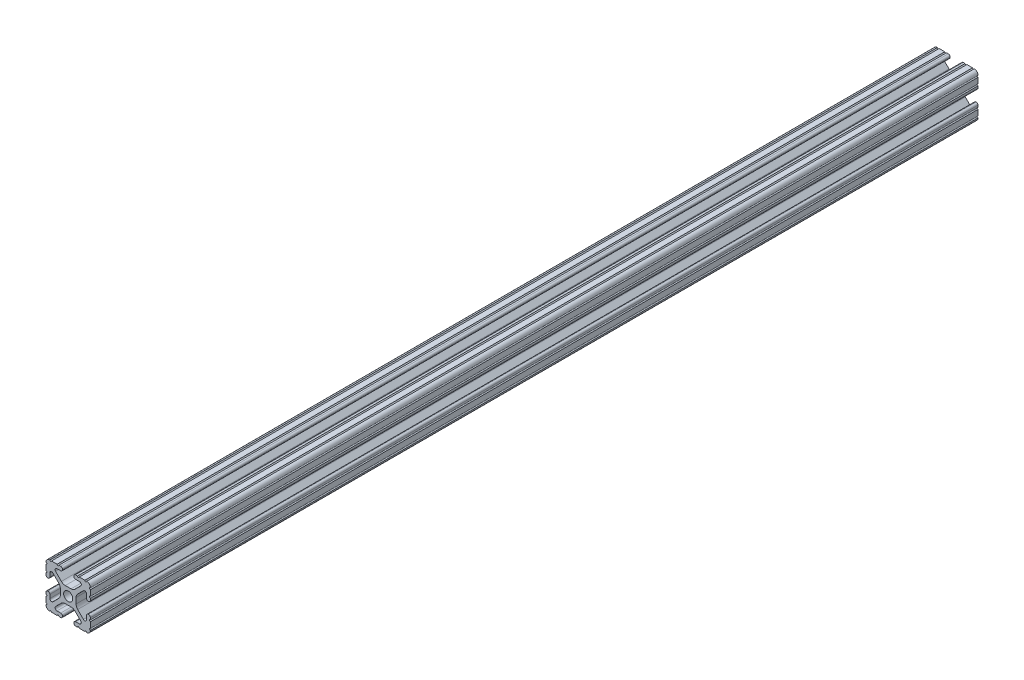
from build123d import *

# Parameters (mm, degrees)
SKETCH1_R           = 2.6035
BOSS_EXTRUDE1_DEPTH = 254


with BuildPart() as part:
    # Sketch1 → Boss-Extrude1 (new body, symmetric)
    with BuildSketch(Plane.XY):
        with BuildLine():
            Line((-7.179650497, -8.645192506), (-3.952270251, -5.423690499))
            ThreePointArc((-3.952270251, -5.423690499), (-2.922936451, -4.736929036), (-1.709253557, -4.4958))
            Line((-1.709253557, -4.4958), (1.709253557, -4.4958))
            ThreePointArc((1.709253557, -4.4958), (2.922936451, -4.736929036), (3.952270251, -5.423690499))
            Line((3.952270251, -5.423690499), (7.179650497, -8.645192506))
            ThreePointArc((7.179650497, -8.645192506), (7.41473083, -9.822813117), (6.416408329, -10.4902))
            Line((6.416408329, -10.4902), (4.287512407, -10.4902))
            ThreePointArc((4.287512407, -10.4902), (3.54574862, -10.79744862), (3.2385, -11.539212407))
            Line((3.2385, -11.539212407), (3.2385, -11.650987593))
            ThreePointArc((3.2385, -11.650987593), (3.54574862, -12.39275138), (4.287512407, -12.7))
            Line((4.287512407, -12.7), (5.317126718, -12.7))
            ThreePointArc((5.317126718, -12.7), (5.825126718, -12.192), (6.333126718, -12.7))
            Line((6.333126718, -12.7), (9.550443118, -12.7))
            ThreePointArc((9.550443118, -12.7), (10.058366869, -12.192000006), (10.566443095, -12.699847501))
            ThreePointArc((10.566443095, -12.699847501), (12.082537762, -12.08250727), (12.699846982, -10.566399977))
            ThreePointArc((12.699846982, -10.566399977), (12.192000006, -10.058323491), (12.7, -9.5504))
            Line((12.7, -9.5504), (12.7, -6.3330836))
            ThreePointArc((12.7, -6.3330836), (12.192, -5.8250836), (12.7, -5.3170836))
            Line((12.7, -5.3170836), (12.7, -4.287469289))
            ThreePointArc((12.7, -4.287469289), (12.39275138, -3.545705502), (11.650987593, -3.238456882))
            Line((11.650987593, -3.238456882), (11.539212407, -3.238456882))
            ThreePointArc((11.539212407, -3.238456882), (10.79744862, -3.545705502), (10.4902, -4.287469289))
            Line((10.4902, -4.287469289), (10.4902, -6.402089023))
            ThreePointArc((10.4902, -6.402089023), (9.856505071, -7.351067942), (8.737131347, -7.129408934))
            Line((8.737131347, -7.129408934), (5.441005833, -3.840816462))
            ThreePointArc((5.441005833, -3.840816462), (4.750877967, -2.809883091), (4.5085, -1.593185507))
            Line((4.5085, -1.593185507), (4.5085, 1.593185507))
            ThreePointArc((4.5085, 1.593185507), (4.750877967, 2.809883091), (5.441005833, 3.840816462))
            Line((5.441005833, 3.840816462), (8.737131347, 7.129408934))
            ThreePointArc((8.737131347, 7.129408934), (9.856505071, 7.351067942), (10.4902, 6.402089023))
            Line((10.4902, 6.402089023), (10.4902, 4.287469289))
            ThreePointArc((10.4902, 4.287469289), (10.79744862, 3.545705502), (11.539212407, 3.238456882))
            Line((11.539212407, 3.238456882), (11.650987593, 3.238456882))
            ThreePointArc((11.650987593, 3.238456882), (12.39275138, 3.545705502), (12.7, 4.287469289))
            Line((12.7, 4.287469289), (12.7, 5.3170836))
            ThreePointArc((12.7, 5.3170836), (12.192, 5.8250836), (12.7, 6.3330836))
            Line((12.7, 6.3330836), (12.7, 9.5504))
            ThreePointArc((12.7, 9.5504), (12.192000006, 10.058323491), (12.699846982, 10.566399977))
            ThreePointArc((12.699846982, 10.566399977), (12.082537762, 12.08250727), (10.566443095, 12.699847501))
            ThreePointArc((10.566443095, 12.699847501), (10.058366869, 12.192000006), (9.550443118, 12.7))
            Line((9.550443118, 12.7), (6.333126718, 12.7))
            ThreePointArc((6.333126718, 12.7), (5.825126718, 12.192), (5.317126718, 12.7))
            Line((5.317126718, 12.7), (4.287512407, 12.7))
            ThreePointArc((4.287512407, 12.7), (3.54574862, 12.39275138), (3.2385, 11.650987593))
            Line((3.2385, 11.650987593), (3.2385, 11.539212407))
            ThreePointArc((3.2385, 11.539212407), (3.54574862, 10.79744862), (4.287512407, 10.4902))
            Line((4.287512407, 10.4902), (6.476788598, 10.4902))
            ThreePointArc((6.476788598, 10.4902), (7.432222385, 9.85140422), (7.207036008, 8.724370562))
            Line((7.207036008, 8.724370562), (3.898272566, 5.423169045))
            ThreePointArc((3.898272566, 5.423169045), (2.869120213, 4.736787962), (1.655778399, 4.4958))
            Line((1.655778399, 4.4958), (-1.655778399, 4.4958))
            ThreePointArc((-1.655778399, 4.4958), (-2.869120213, 4.736787962), (-3.898272566, 5.423169045))
            Line((-3.898272566, 5.423169045), (-7.207036008, 8.724370562))
            ThreePointArc((-7.207036008, 8.724370562), (-7.432222385, 9.85140422), (-6.476788598, 10.4902))
            Line((-6.476788598, 10.4902), (-4.287512407, 10.4902))
            ThreePointArc((-4.287512407, 10.4902), (-3.54574862, 10.79744862), (-3.2385, 11.539212407))
            Line((-3.2385, 11.539212407), (-3.2385, 11.650987593))
            ThreePointArc((-3.2385, 11.650987593), (-3.54574862, 12.39275138), (-4.287512407, 12.7))
            Line((-4.287512407, 12.7), (-5.317126718, 12.7))
            ThreePointArc((-5.317126718, 12.7), (-5.825126718, 12.192), (-6.333126718, 12.7))
            Line((-6.333126718, 12.7), (-9.550443118, 12.7))
            ThreePointArc((-9.550443118, 12.7), (-10.058366869, 12.192000006), (-10.566443095, 12.699847501))
            ThreePointArc((-10.566443095, 12.699847501), (-12.082537762, 12.08250727), (-12.699846982, 10.566399977))
            ThreePointArc((-12.699846982, 10.566399977), (-12.192000006, 10.058323491), (-12.7, 9.5504))
            Line((-12.7, 9.5504), (-12.7, 6.3330836))
            ThreePointArc((-12.7, 6.3330836), (-12.192, 5.8250836), (-12.7, 5.3170836))
            Line((-12.7, 5.3170836), (-12.7, 4.287469289))
            ThreePointArc((-12.7, 4.287469289), (-12.39275138, 3.545705502), (-11.650987593, 3.238456882))
            Line((-11.650987593, 3.238456882), (-11.539212407, 3.238456882))
            ThreePointArc((-11.539212407, 3.238456882), (-10.79744862, 3.545705502), (-10.4902, 4.287469289))
            Line((-10.4902, 4.287469289), (-10.4902, 6.402089023))
            ThreePointArc((-10.4902, 6.402089023), (-9.856505071, 7.351067942), (-8.737131347, 7.129408934))
            Line((-8.737131347, 7.129408934), (-5.441005833, 3.840816462))
            ThreePointArc((-5.441005833, 3.840816462), (-4.750877967, 2.809883091), (-4.5085, 1.593185507))
            Line((-4.5085, 1.593185507), (-4.5085, -1.593185507))
            ThreePointArc((-4.5085, -1.593185507), (-4.750877967, -2.809883091), (-5.441005833, -3.840816462))
            Line((-5.441005833, -3.840816462), (-8.737131347, -7.129408934))
            ThreePointArc((-8.737131347, -7.129408934), (-9.856505071, -7.351067942), (-10.4902, -6.402089023))
            Line((-10.4902, -6.402089023), (-10.4902, -4.287469289))
            ThreePointArc((-10.4902, -4.287469289), (-10.79744862, -3.545705502), (-11.539212407, -3.238456882))
            Line((-11.539212407, -3.238456882), (-11.650987593, -3.238456882))
            ThreePointArc((-11.650987593, -3.238456882), (-12.39275138, -3.545705502), (-12.7, -4.287469289))
            Line((-12.7, -4.287469289), (-12.7, -5.3170836))
            ThreePointArc((-12.7, -5.3170836), (-12.192, -5.8250836), (-12.7, -6.3330836))
            Line((-12.7, -6.3330836), (-12.7, -9.5504))
            ThreePointArc((-12.7, -9.5504), (-12.192000006, -10.058323491), (-12.699846982, -10.566399977))
            ThreePointArc((-12.699846982, -10.566399977), (-12.082537762, -12.08250727), (-10.566443095, -12.699847501))
            ThreePointArc((-10.566443095, -12.699847501), (-10.058366869, -12.192000006), (-9.550443118, -12.7))
            Line((-9.550443118, -12.7), (-6.333126718, -12.7))
            ThreePointArc((-6.333126718, -12.7), (-5.825126718, -12.192), (-5.317126718, -12.7))
            Line((-5.317126718, -12.7), (-4.287512407, -12.7))
            ThreePointArc((-4.287512407, -12.7), (-3.54574862, -12.39275138), (-3.2385, -11.650987593))
            Line((-3.2385, -11.650987593), (-3.2385, -11.539212407))
            ThreePointArc((-3.2385, -11.539212407), (-3.54574862, -10.79744862), (-4.287512407, -10.4902))
            Line((-4.287512407, -10.4902), (-6.416408329, -10.4902))
            ThreePointArc((-6.416408329, -10.4902), (-7.41473083, -9.822813117), (-7.179650497, -8.645192506))
        make_face()
        Circle(SKETCH1_R, mode=Mode.SUBTRACT)
    extrude(amount=BOSS_EXTRUDE1_DEPTH, both=True)


solid = part.part
